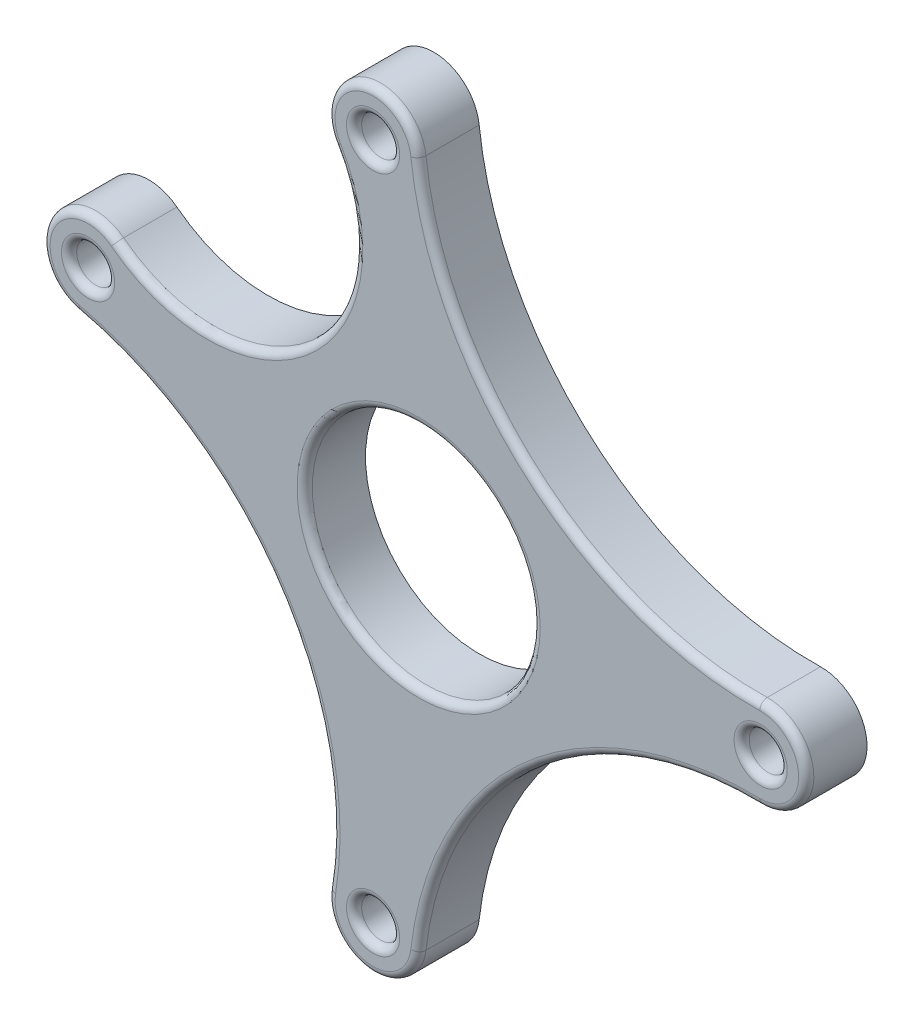
from build123d import *

# Parameters (mm, degrees)
ESBO_O1_R                = 15
ESBO_O1_R_2              = 2.5
RESSALTO_EXTRUS_O1_DEPTH = 8
FILETE1_R                = 1
FILETE2_R                = 1


with BuildPart() as part:
    # Esboço1 → Ressalto-extrusão1 (new body)
    with BuildSketch(Plane.XY):
        with BuildLine():
            ThreePointArc((-0.038300091, 45.27685611), (-7.929774474, 50.281194459), (-11.140539582, 41.505674095))
            ThreePointArc((-11.140539582, 41.505674095), (-14.900894737, 16.858665244), (-39.81962046, 16.038650276))
            ThreePointArc((-39.81962046, 16.038650276), (-48.920699174, 13.872162606), (-44.842958612, 5.452225879))
            ThreePointArc((-44.842958612, 5.452225879), (-18.66344626, -12.566891498), (-11.920192616, -43.624643966))
            ThreePointArc((-11.920192616, -43.624643966), (-6.826366721, -50.542820714), (-0.038300091, -45.27685611))
            ThreePointArc((-0.038300091, -45.27685611), (14.810761943, -16.937866796), (44.876158422, -5.998721802))
            ThreePointArc((44.876158422, -5.998721802), (51, 0), (44.876158422, 5.998721802))
            ThreePointArc((44.876158422, 5.998721802), (14.810761943, 16.937866796), (-0.038300091, 45.27685611))
        make_face()
        Circle(ESBO_O1_R, mode=Mode.SUBTRACT)
        with Locations((-6, 44.6)):
            Circle(ESBO_O1_R_2, mode=Mode.SUBTRACT)
        with Locations((45, 0)):
            Circle(ESBO_O1_R_2, mode=Mode.SUBTRACT)
        with Locations((-43.5, 11.3)):
            Circle(ESBO_O1_R_2, mode=Mode.SUBTRACT)
        with Locations((-6, -44.6)):
            Circle(ESBO_O1_R_2, mode=Mode.SUBTRACT)
    extrude(amount=RESSALTO_EXTRUS_O1_DEPTH)

    # Filete1
    filete1_edges = [part.edges().sort_by_distance(p)[0] for p in [
        (-15, 0, 8),
    ]]
    fillet(filete1_edges, radius=FILETE1_R)

    # Filete2
    filete2_edges = [part.edges().sort_by_distance(p)[0] for p in [
        (-48.920699174, 13.872162606, 8),
        (-18.66344626, -12.566891498, 8),
        (-6.826366721, -50.542820714, 8),
        (14.810761943, -16.937866796, 8),
        (51, 0, 8),
        (-46, 11.3, 8),
        (14.810761943, 16.937866796, 8),
        (-8.5, 44.6, 8),
        (42.5, 0, 8),
        (-8.5, -44.6, 8),
        (-7.929774474, 50.281194459, 8),
        (-14.900894737, 16.858665244, 8),
    ]]
    fillet(filete2_edges, radius=FILETE2_R)


solid = part.part
